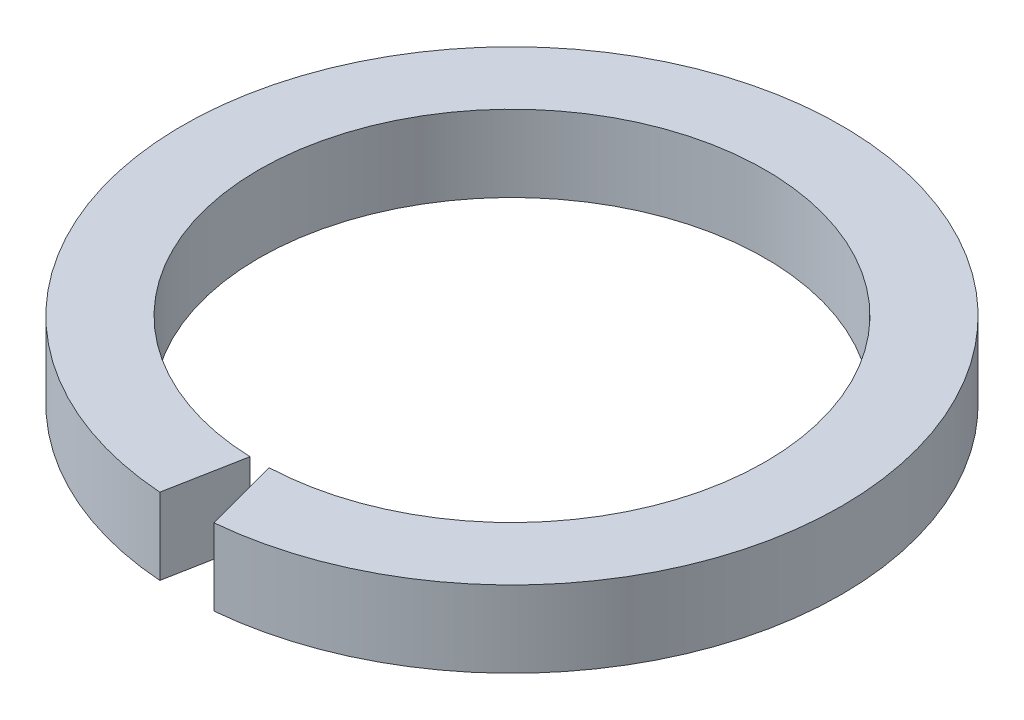
from build123d import *

# Parameters (mm, degrees)
SKETCH1_R               = 21.55
SKETCH1_R_2             = 16.55
BOSS_EXTRUDE1_DEPTH     = 5
CUT_EXTRUDE2_DEPTH      = 15
CUT_EXTRUDE2_DEPTH_BACK = 12


with BuildPart() as part:
    # Sketch1 → Boss-Extrude1 (new body)
    with BuildSketch(Plane(origin=(0, 0, 0), x_dir=(1, 0, 0), z_dir=(0, 1, 0))):
        Circle(SKETCH1_R)
        Circle(SKETCH1_R_2, mode=Mode.SUBTRACT)
    extrude(amount=BOSS_EXTRUDE1_DEPTH)

    # Sketch3 → Cut-Extrude2 (cut, two sides)
    with BuildSketch(Plane(origin=(0, 0, 0), x_dir=(1, 0, 0), z_dir=(0, 1, 0))) as cut_extrude2_sk:
        Polygon((-1.758392575, -22.689237535), (2.305538937, -22.689237535), (0.504822735, -15.993131255), (0, -15.993131255), (-0.488859737, -15.993131255), align=None)
    extrude(amount=CUT_EXTRUDE2_DEPTH, mode=Mode.SUBTRACT)
    extrude(cut_extrude2_sk.sketch, amount=-CUT_EXTRUDE2_DEPTH_BACK, mode=Mode.SUBTRACT)


solid = part.part
